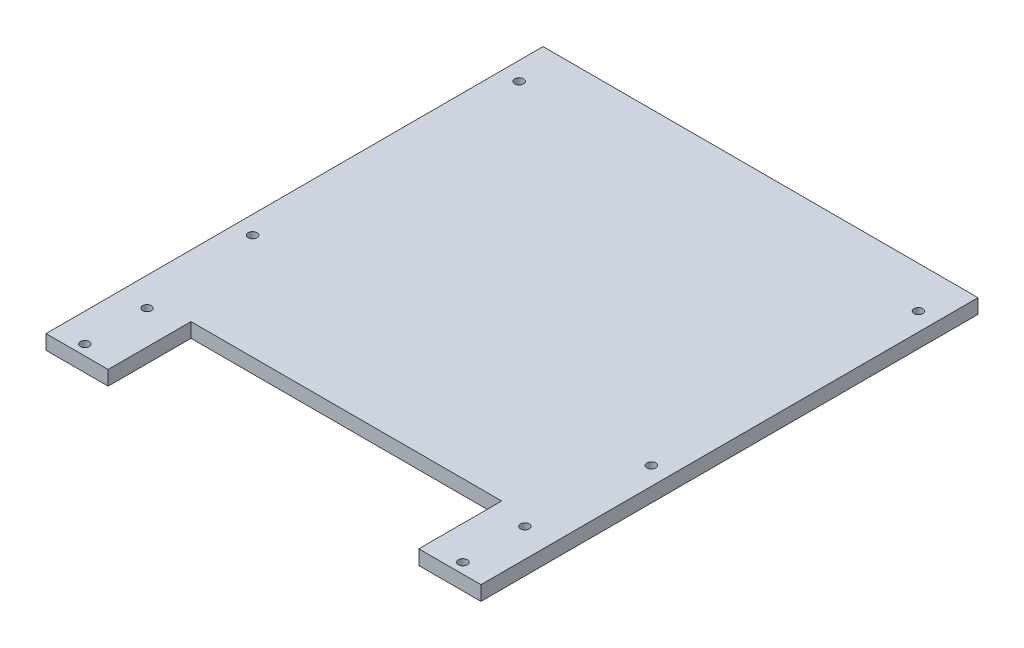
from build123d import *

# Parameters (mm, degrees)
SALIENTE_EXTRUIR1_DEPTH = 14
CROQUIS2_R              = 4.25
CORTAR_EXTRUIR1_DEPTH   = 15


with BuildPart() as part:
    # Croquis1 → Saliente-Extruir1 (new body)
    with BuildSketch(Plane(origin=(0, 0, 0), x_dir=(1, 0, 0), z_dir=(0, 1, 0))):
        Polygon((150, -240), (210, -240), (210, 240), (-210, 240), (-210, -240), (-150, -240), (-150, -160), (150, -160), align=None)
    extrude(amount=SALIENTE_EXTRUIR1_DEPTH)

    # Croquis2 → Cortar-Extruir1 (cut, through all)
    with BuildSketch(Plane(origin=(0, 14, 0), x_dir=(1, 0, 0), z_dir=(0, 1, 0))):
        with Locations((-182.5, -230.00000008)):
            Circle(CROQUIS2_R)
        with Locations((-182.5, -170.00000008)):
            Circle(CROQUIS2_R)
        with Locations((-192.5, -58)):
            Circle(CROQUIS2_R)
        with Locations((-192.5, 199.388515843)):
            Circle(CROQUIS2_R)
        with Locations((192.499514399, 200)):
            Circle(CROQUIS2_R)
        with Locations((192.5, -58)):
            Circle(CROQUIS2_R)
        with Locations((182.5, -170)):
            Circle(CROQUIS2_R)
        with Locations((182.5, -230)):
            Circle(CROQUIS2_R)
    extrude(amount=-CORTAR_EXTRUIR1_DEPTH, mode=Mode.SUBTRACT)


solid = part.part
